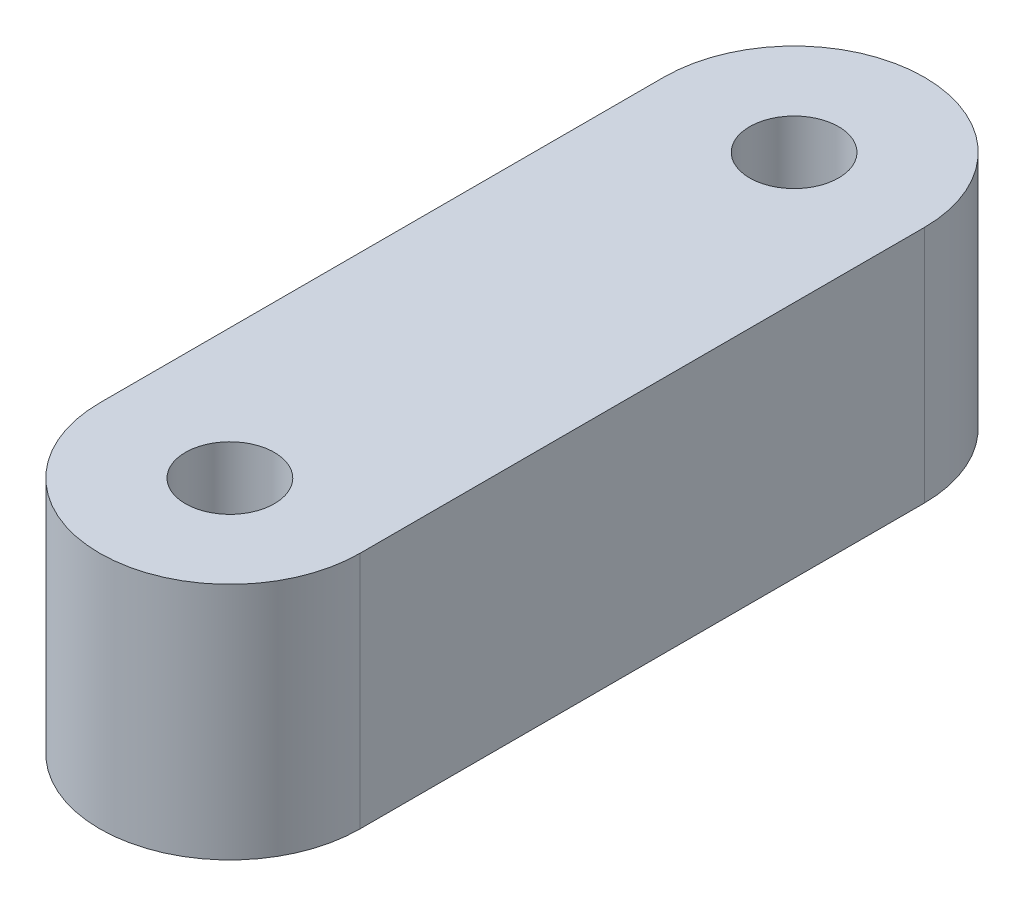
from build123d import *

# Parameters (mm, degrees)
EXTRUDE_1_DEPTH     = 11
SKETCH_2_R          = 2.05
CUT_EXTRUDE_1_DEPTH = 12
SKETCH_3_R          = 3.6
CUT_EXTRUDE_2_DEPTH = 10
EXTRUDE_3_DEPTH     = 10


with BuildPart() as part:
    # 草图1 → 凸台-拉伸1 (new body)
    with BuildSketch(Plane(origin=(0, 0, 0), x_dir=(1, 0, 0), z_dir=(0, 1, 0))):
        with BuildLine():
            Line((-6, -13), (-6, 13))
            ThreePointArc((-6, 13), (0, 19), (6, 13))
            Line((6, 13), (6, -13))
            ThreePointArc((6, -13), (0, -19), (-6, -13))
        make_face()
    extrude(amount=EXTRUDE_1_DEPTH)

    # 草图2 → 切除-拉伸1 (cut, through all)
    with BuildSketch(Plane(origin=(0, 11, 0), x_dir=(1, 0, 0), z_dir=(0, 1, 0))):
        with Locations((0, 13)):
            Circle(SKETCH_2_R)
        with Locations((0, -13)):
            Circle(SKETCH_2_R)
    extrude(amount=-CUT_EXTRUDE_1_DEPTH, mode=Mode.SUBTRACT)

    # 草图3 → 切除-拉伸2 (cut)
    with BuildSketch(Plane.ZY.offset(6)):
        with Locations((0, 5.5)):
            Circle(SKETCH_3_R)
    extrude(amount=-CUT_EXTRUDE_2_DEPTH, mode=Mode.SUBTRACT)

    # 草图4 → 凸台-拉伸3 (add)
    with BuildSketch(Plane.ZY.offset(6)):
        with BuildLine():
            Line((2.959307351, 3.45), (-2.959307351, 3.45))
            ThreePointArc((-2.959307351, 3.45), (0, 1.9), (2.959307351, 3.45))
        make_face()
    extrude(amount=-EXTRUDE_3_DEPTH)


solid = part.part
